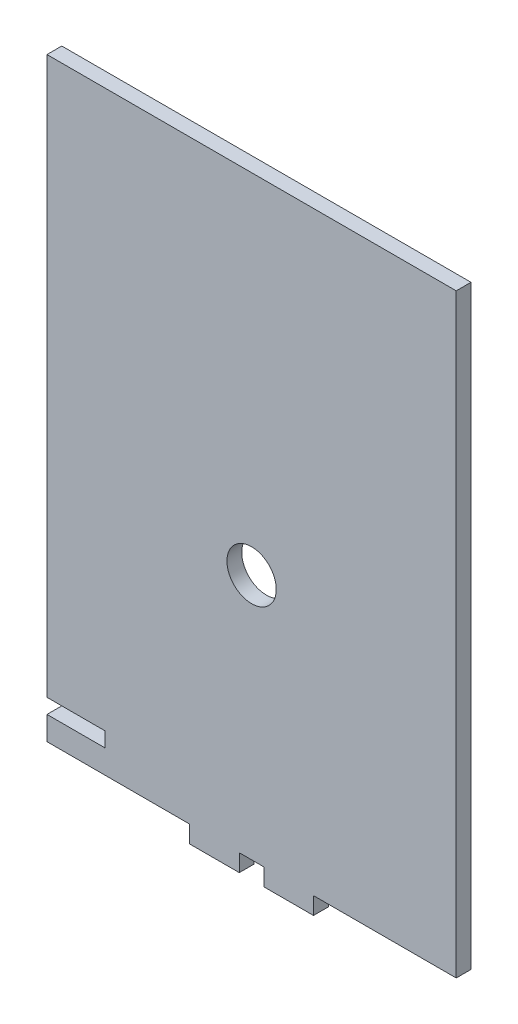
from build123d import *

# Parameters (mm, degrees)
MODEL_R                 = 5
SALIENTE_EXTRUIR1_DEPTH = 3


with BuildPart() as part:
    # Model → Saliente-Extruir1 (new body)
    with BuildSketch(Plane.XY):
        Polygon((43.835480064, -35.842547763), (43.835480064, -32.349014415), (14.885477826, -32.340639111), (14.885479202, -27.550194175), (26.685480393, -27.550194175), (26.685480393, -24.550194175), (14.885480064, -24.550193732), (14.885483847, -5.553308235), (14.885503897, 88.349821578), (97.885505249, 88.349799035), (97.885505249, -32.347086905), (68.935480064, -32.349014415), (68.935480064, -35.842547763), (58.885480064, -35.842547763), (58.885480064, -32.342547763), (53.885480064, -32.342547763), (53.885480064, -35.842547763), align=None)
        with Locations((56.385505249, 17.649799035)):
            Circle(MODEL_R, mode=Mode.SUBTRACT)
    extrude(amount=SALIENTE_EXTRUIR1_DEPTH)


solid = part.part
